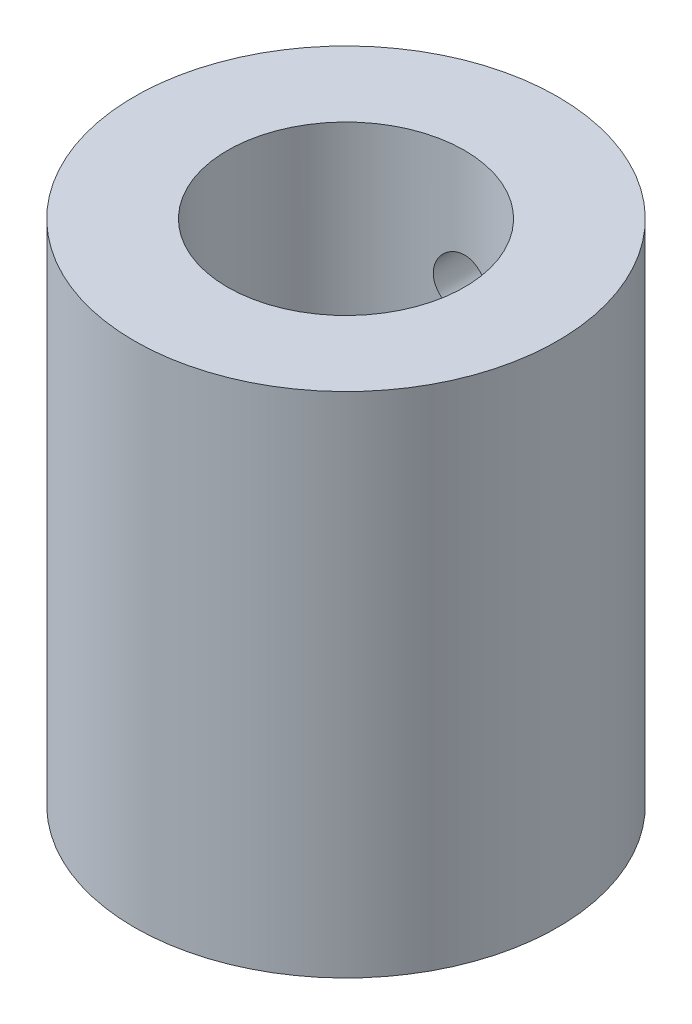
from build123d import *

# Parameters (mm, degrees)
SKETCH1_R           = 12.5
BOSS_EXTRUDE1_DEPTH = 30
SKETCH2_R           = 7
CUT_EXTRUDE1_DEPTH  = 23
CUT_EXTRUDE3_DEPTH  = 7.6
SKETCH6_R           = 1
CUT_EXTRUDE4_DEPTH  = 7.6
FILLET2_R           = 1
SKETCH7_R           = 1.65
CUT_EXTRUDE5_DEPTH  = 19.5


with BuildPart() as part:
    # Sketch1 → Boss-Extrude1 (new body)
    with BuildSketch(Plane(origin=(0, 0, 0), x_dir=(1, 0, 0), z_dir=(0, 1, 0))):
        Circle(SKETCH1_R)
    extrude(amount=BOSS_EXTRUDE1_DEPTH)

    # Sketch2 → Cut-Extrude1 (cut)
    with BuildSketch(Plane(origin=(0, 30, 0), x_dir=(1, 0, 0), z_dir=(0, 1, 0))):
        Circle(SKETCH2_R)
    extrude(amount=-CUT_EXTRUDE1_DEPTH, mode=Mode.SUBTRACT)

    # Sketch5 → Cut-Extrude3 (cut)
    with BuildSketch(Plane(origin=(0, 0, 0), x_dir=(-1, 0, 0), z_dir=(0, -1, 0))):
        with BuildLine():
            Line((2.383275058, 3.15), (8.803408431, 3.15))
            ThreePointArc((8.803408431, 3.15), (9.35, 0), (8.803408431, -3.15))
            Line((8.803408431, -3.15), (2.383275058, -3.15))
            ThreePointArc((2.383275058, -3.15), (0, -3.95), (-2.383275058, -3.15))
            Line((-2.383275058, -3.15), (-8.803408431, -3.15))
            ThreePointArc((-8.803408431, -3.15), (-9.35, 0), (-8.803408431, 3.15))
            Line((-8.803408431, 3.15), (-2.383275058, 3.15))
            ThreePointArc((-2.383275058, 3.15), (0, 3.95), (2.383275058, 3.15))
        make_face()
    extrude(amount=-CUT_EXTRUDE3_DEPTH, mode=Mode.SUBTRACT)

    # Sketch6 → Cut-Extrude4 (cut)
    with BuildSketch(Plane.XZ):
        with Locations((-8.167012328, 2.513603897)):
            Circle(SKETCH6_R)
        with Locations((8.167012328, 2.513603897)):
            Circle(SKETCH6_R)
        with Locations((8.167012328, -2.513603897)):
            Circle(SKETCH6_R)
        with Locations((-8.167012328, -2.513603897)):
            Circle(SKETCH6_R)
    extrude(amount=-CUT_EXTRUDE4_DEPTH, mode=Mode.SUBTRACT)

    # Fillet2
    fillet2_edges = [part.edges().sort_by_distance(p)[0] for p in [
        (-9.099116447, 3.8, 2.151413462),
        (-7.395649897, 3.8, 3.15),
        (9.099116447, 3.8, -2.151413462),
        (9.099116447, 3.8, 2.151413462),
        (-9.099116447, 3.8, -2.151413462),
        (7.395649897, 3.8, 3.15),
        (7.395649897, 3.8, -3.15),
        (-7.395649897, 3.8, -3.15),
    ]]
    fillet(fillet2_edges, radius=FILLET2_R)

    # Sketch7 → Cut-Extrude5 (cut)
    with BuildSketch(Plane.XY):
        with Locations((0, 23)):
            Circle(SKETCH7_R)
    extrude(amount=-CUT_EXTRUDE5_DEPTH, mode=Mode.SUBTRACT)


solid = part.part
